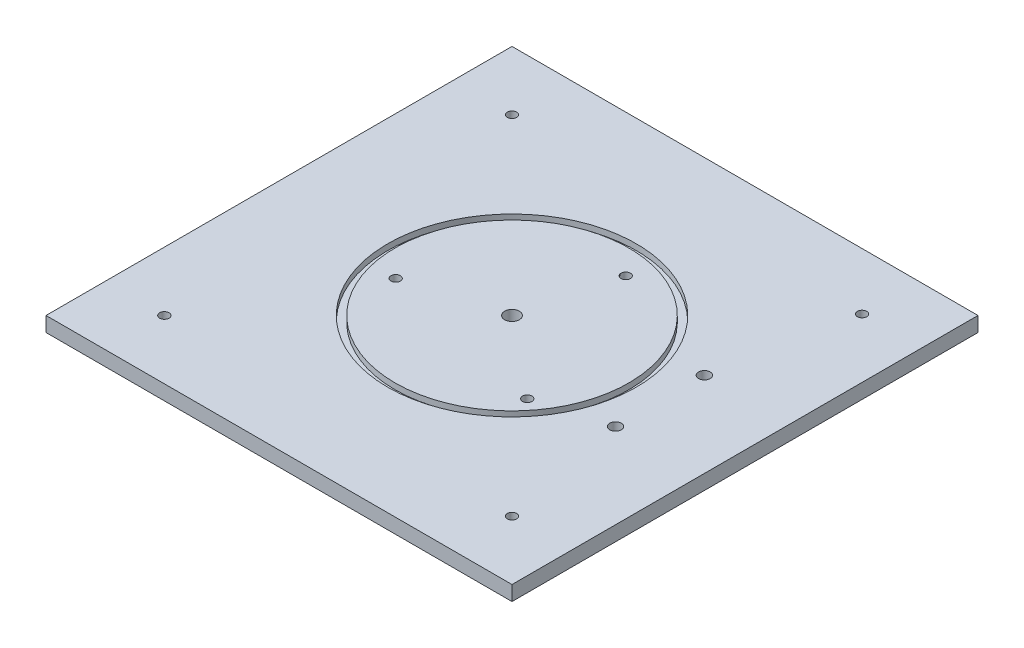
from build123d import *

# Parameters (mm, degrees)
SKETCH1_W                  = 200
SKETCH1_H                  = 200
BOSS_EXTRUDE1_DEPTH        = 6.35
SKETCH2_R                  = 3.175
CUT_EXTRUDE1_DEPTH         = 7.35
SKETCH3_R                  = 2.4892
CUT_EXTRUDE2_DEPTH         = 7.35
SKETCH4_R                  = 53.34
SKETCH4_R_2                = 50.165
CUT_EXTRUDE3_DEPTH         = 2.54
F_10_32_TAPPED_HOLE1_D     = 4.0386
F_10_32_TAPPED_HOLE1_DEPTH = 13.716
F_10_32_TAPPED_HOLE1_TIP   = 1.213317848
SKETCH9_R                  = 2.02
SKETCH9_R_2                = 2.032
CUT_EXTRUDE4_DEPTH         = 7.35


with BuildPart() as part:
    # Sketch1 → Boss-Extrude1 (new body)
    with BuildSketch(Plane(origin=(0, 0, 0), x_dir=(1, 0, 0), z_dir=(0, 1, 0))):
        Rectangle(SKETCH1_W, SKETCH1_H)
    extrude(amount=BOSS_EXTRUDE1_DEPTH)

    # Sketch2 → Cut-Extrude1 (cut, through all)
    with BuildSketch(Plane(origin=(0, 6.35, 0), x_dir=(1, 0, 0), z_dir=(0, 1, 0))):
        Circle(SKETCH2_R)
    extrude(amount=-CUT_EXTRUDE1_DEPTH, mode=Mode.SUBTRACT)

    # Sketch3 → Cut-Extrude2 (cut, through all)
    with BuildSketch(Plane(origin=(0, 6.35, 0), x_dir=(1, 0, 0), z_dir=(0, 1, 0))):
        with Locations((63.5, -19.05)):
            Circle(SKETCH3_R)
        with Locations((63.5, 19.05)):
            Circle(SKETCH3_R)
    extrude(amount=-CUT_EXTRUDE2_DEPTH, mode=Mode.SUBTRACT)

    # Sketch4 → Cut-Extrude3 (cut)
    with BuildSketch(Plane(origin=(0, 6.35, 0), x_dir=(1, 0, 0), z_dir=(0, 1, 0))):
        Circle(SKETCH4_R)
        Circle(SKETCH4_R_2, mode=Mode.SUBTRACT)
    extrude(amount=-CUT_EXTRUDE3_DEPTH, mode=Mode.SUBTRACT)

    # #10-32 Tapped Hole1
    with Locations(Plane(origin=(0, 6.35, 0), x_dir=(1, 0, 0), z_dir=(0, 1, 0))):
        with Locations((9.693302756, 39.140054777), (-38.74293312, -11.175380955), (34.225642894, -27.683137416)):
            Hole(F_10_32_TAPPED_HOLE1_D / 2, depth=F_10_32_TAPPED_HOLE1_DEPTH)
            with Locations((0, 0, -(F_10_32_TAPPED_HOLE1_DEPTH + F_10_32_TAPPED_HOLE1_TIP / 2))):  # 118° drill point
                Cone(0, F_10_32_TAPPED_HOLE1_D / 2, F_10_32_TAPPED_HOLE1_TIP, mode=Mode.SUBTRACT)

    # Sketch9 → Cut-Extrude4 (cut, through all)
    with BuildSketch(Plane(origin=(0, 6.35, 0), x_dir=(1, 0, 0), z_dir=(0, 1, 0))):
        with Locations((-74.6, 74.6)):
            Circle(SKETCH9_R)
        with Locations((74.6, 75.660597777)):
            Circle(SKETCH9_R)
        with Locations((74.6, -74.6)):
            Circle(SKETCH9_R)
        with Locations((-74.6, -74.6)):
            Circle(SKETCH9_R_2)
    extrude(amount=-CUT_EXTRUDE4_DEPTH, mode=Mode.SUBTRACT)


solid = part.part
